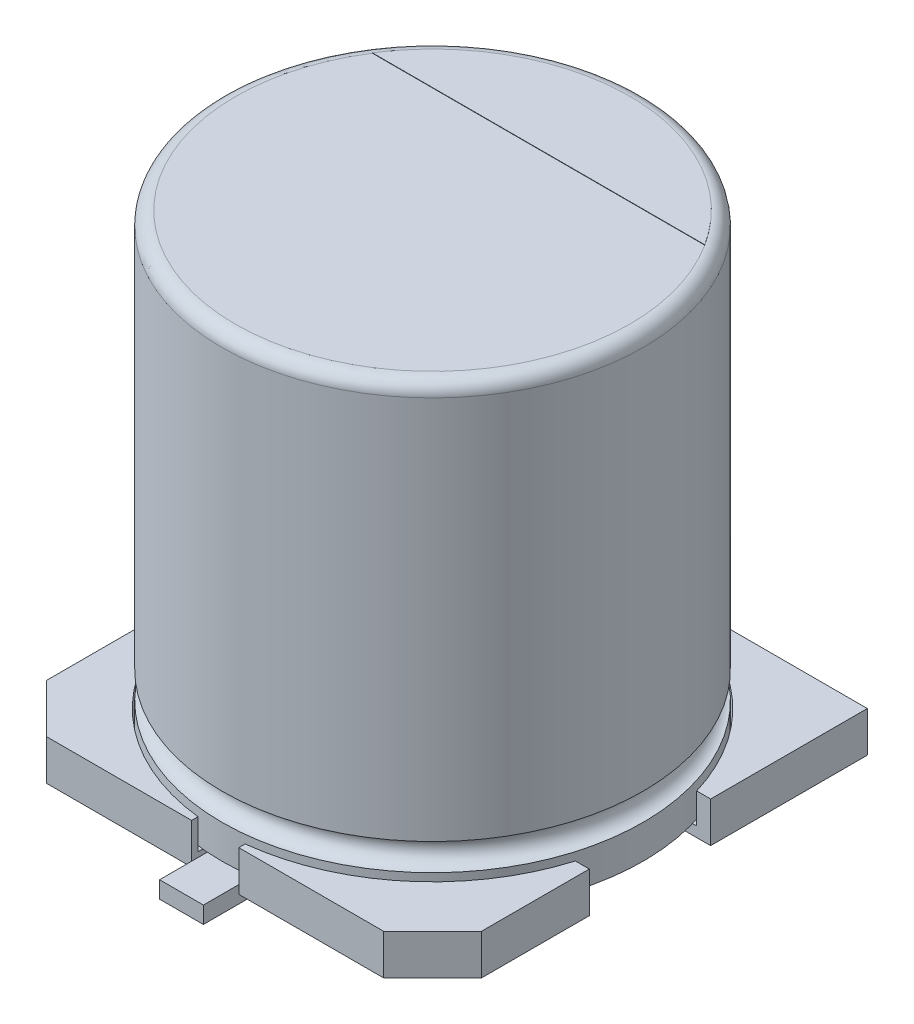
from build123d import *

# Parameters (mm, degrees)
BOSS_EXTRUDE1_DEPTH = 1.2
CUT_EXTRUDE1_START  = 1.2
SKETCH4_R           = 6.3
CUT_EXTRUDE1_DEPTH  = 0.9
BOSS_EXTRUDE2_DEPTH = 0.65
BOSS_EXTRUDE3_DEPTH = 0.01


with BuildPart() as part:
    # Sketch1 → Boss-Extrude1 (new body)
    with BuildSketch(Plane(origin=(0, 0, 0), x_dir=(1, 0, 0), z_dir=(0, 1, 0))):
        Polygon((-6.45, 6.45), (-0.7, 6.45), (-0.7, 5.932376892), (0.7, 5.932376892), (0.7, 6.45), (6.45, 6.45), (6.45, 1.8), (4.866153182, 1.8), (4.866153182, -1.8), (6.45, -1.8), (6.45, -5), (5, -6.45), (0.7, -6.45), (0.7, -5.932376892), (-0.7, -5.932376892), (-0.7, -6.45), (-5, -6.45), (-6.45, -5), (-6.45, -1.8), (-4.866153182, -1.8), (-4.866153182, 1.8), (-6.45, 1.8), align=None)
    extrude(amount=BOSS_EXTRUDE1_DEPTH)

    # Sketch4 → Cut-Extrude1 (cut)
    with BuildSketch(Plane(origin=(0, 0, 0), x_dir=(1, 0, 0), z_dir=(0, 1, 0)).offset(CUT_EXTRUDE1_START)):
        Circle(SKETCH4_R)
    extrude(amount=-CUT_EXTRUDE1_DEPTH, mode=Mode.SUBTRACT)

    # Sketch5 → Boss-Extrude2 (add, symmetric)
    with BuildSketch(Plane(origin=(0, 0, 0), x_dir=(0, 0, -1), z_dir=(1, 0, 0))):
        with BuildLine():
            Line((-7.45, 0.2), (-7.45, -0.3))
            Line((-7.45, -0.3), (-3.741421356, -0.3))
            ThreePointArc((-3.741421356, -0.3), (-3.703153013, -0.292387953), (-3.670710678, -0.270710678))
            Line((-3.670710678, -0.270710678), (-3.479289322, -0.079289322))
            ThreePointArc((-3.479289322, -0.079289322), (-3.457612047, -0.046846987), (-3.45, -0.008578644))
            Line((-3.45, -0.008578644), (-3.45, 0.2))
            Line((-3.45, 0.2), (-7.45, 0.2))
        make_face()
    boss_extrude2 = extrude(amount=BOSS_EXTRUDE2_DEPTH, both=True)

    # Mirror1: Boss-Extrude2 across plane
    add(boss_extrude2.mirror(Plane.XY))


with BuildPart() as body_2:
    # Sketch3 → Revolve1 (revolve)
    with BuildSketch(Plane.XY):
        with BuildLine():
            Line((-6.25, 13.6), (-6.25, 2.2))
            ThreePointArc((-6.25, 2.2), (-5.85, 1.8), (-6.25, 1.4))
            Line((-6.25, 1.4), (-6.25, 0.4))
            Line((-6.25, 0.4), (0, 0.4))
            Line((0, 0.4), (0, 14))
            Line((0, 14), (-5.85, 14))
            ThreePointArc((-5.85, 14), (-6.132842712, 13.882842712), (-6.25, 13.6))
        make_face()
    revolve(axis=Axis((0, 22.223469288, 0), (0, -1, 0)))

    # Sketch6 → Boss-Extrude3 (add)
    with BuildSketch(Plane(origin=(0, 14, 0), x_dir=(1, 0, 0), z_dir=(0, 1, 0))):
        with BuildLine():
            Line((4.932243179, 3.145707746), (-4.932243179, 3.145707746))
            ThreePointArc((-4.932243179, 3.145707746), (0, 5.85), (4.932243179, 3.145707746))
        make_face()
    extrude(amount=BOSS_EXTRUDE3_DEPTH)


solid = Compound([part.part, body_2.part])
